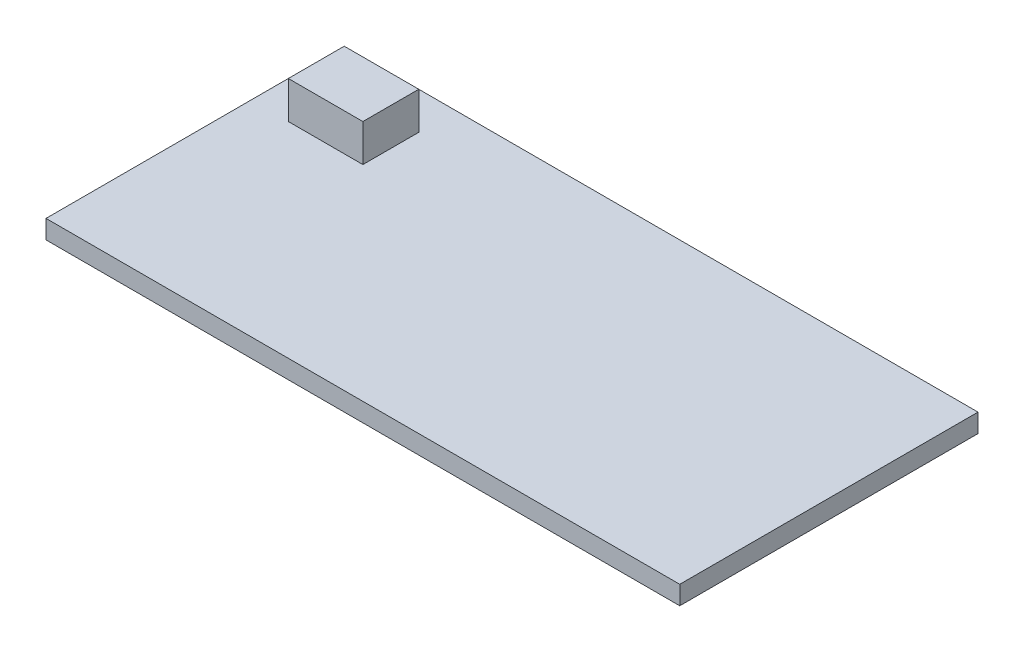
from build123d import *

# Parameters (mm, degrees)
SKETCH1_W           = 170
SKETCH1_H           = 80
BOSS_EXTRUDE1_DEPTH = 5
SKETCH2_W           = 20
SKETCH2_H           = 15
BOSS_EXTRUDE2_DEPTH = 10


with BuildPart() as part:
    # Sketch1 → Boss-Extrude1 (new body)
    with BuildSketch(Plane(origin=(0, 0, 0), x_dir=(1, 0, 0), z_dir=(0, 1, 0))):
        with Locations((85, 40)):
            Rectangle(SKETCH1_W, SKETCH1_H)
    extrude(amount=BOSS_EXTRUDE1_DEPTH)

    # Sketch2 → Boss-Extrude2 (add)
    with BuildSketch(Plane(origin=(0, 5, 0), x_dir=(1, 0, 0), z_dir=(0, 1, 0))):
        with Locations((20, 62.5)):
            Rectangle(SKETCH2_W, SKETCH2_H)
    extrude(amount=BOSS_EXTRUDE2_DEPTH)


solid = part.part
